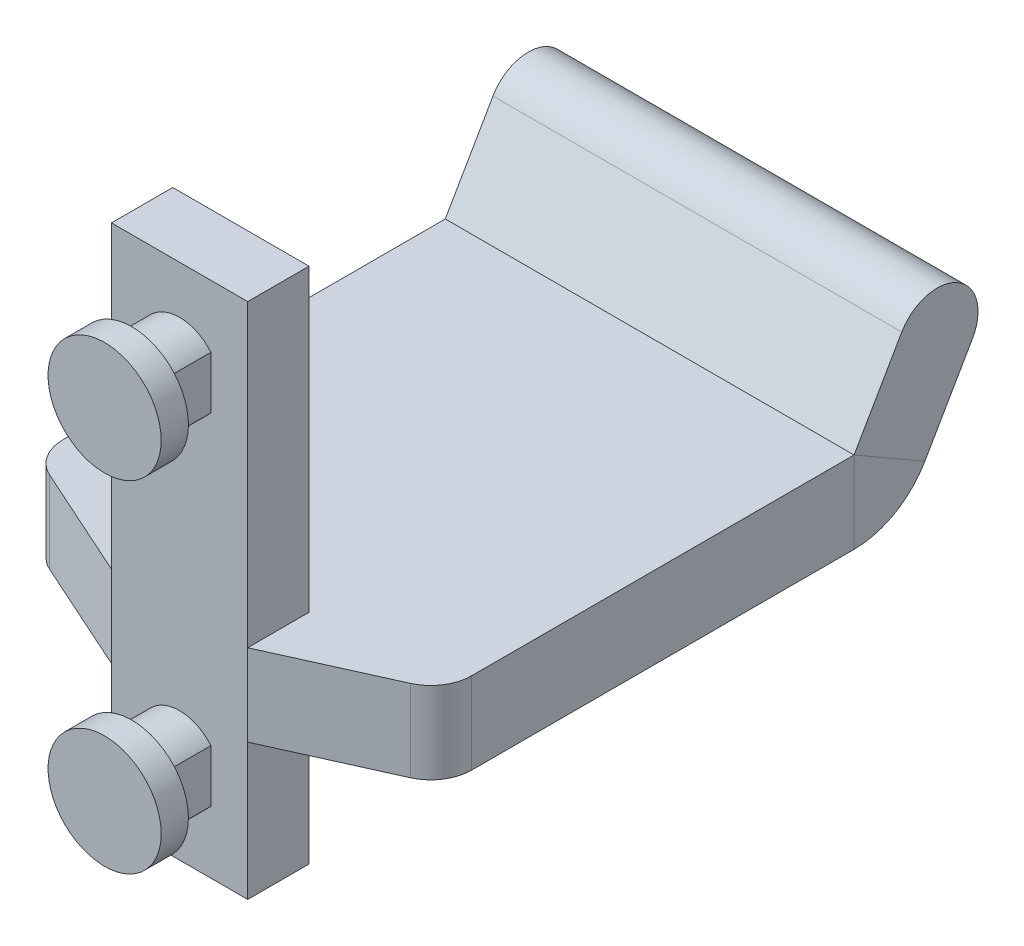
from build123d import *

# Parameters (mm, degrees)
EXTRUDE_1_DEPTH   = 3.5
EXTRUDE_1_2_DEPTH = 3.5
SKETCH_2_R        = 4.15
EXTRUDE_2_DEPTH   = 2
SKETCH_3_W        = 10
SKETCH_3_H        = 38
EXTRUDE_3_DEPTH   = 4.5
SKETCH_5_W        = 30
SKETCH_5_H        = 6
EXTRUDE_4_DEPTH   = 25
EXTRUDE_5_DEPTH   = 6
SKETCH_10_W       = 30
SKETCH_10_H       = 6
SKETCH_11_W       = 30
SKETCH_11_H       = 3
REVOLVE_1_ANGLE   = 180
FILLET_1_R        = 3


with BuildPart() as part:
    # 草图1 → 凸台-拉伸1 (new body)
    with BuildSketch(Plane.XY):
        with BuildLine():
            Line((-2.3, 1.926136028), (-2.3, -1.926136028))
            ThreePointArc((-2.3, -1.926136028), (0, -3), (2.3, -1.926136028))
            Line((2.3, -1.926136028), (2.3, 1.926136028))
            ThreePointArc((2.3, 1.926136028), (0, 3), (-2.3, 1.926136028))
        make_face()
    extrude(amount=EXTRUDE_1_DEPTH)



with BuildPart() as body_2:
    # 草图1 → Extrude 1 2 (new body)
    with BuildSketch(Plane.XY):
        with BuildLine():
            Line((-2.3, -23.073863972), (-2.3, -26.926136028))
            ThreePointArc((-2.3, -26.926136028), (0, -28), (2.3, -26.926136028))
            Line((2.3, -26.926136028), (2.3, -23.073863972))
            ThreePointArc((2.3, -23.073863972), (0, -22), (-2.3, -23.073863972))
        make_face()
    extrude(amount=EXTRUDE_1_2_DEPTH)


with BuildPart() as part_1:
    add(part.part)

    add(body_2.part)  # 凸台-拉伸2 merges body 2
    # 草图2 → 凸台-拉伸2 (add)
    with BuildSketch(Plane.XY.offset(3.5)):
        Circle(SKETCH_2_R)
        with Locations((0, -25)):
            Circle(SKETCH_2_R)
    extrude(amount=EXTRUDE_2_DEPTH)

    # 草图3 → 凸台-拉伸3 (add)
    with BuildSketch(Plane(origin=(0, 0, 0), x_dir=(-1, 0, 0), z_dir=(0, 0, -1))):
        with Locations((0, -12.5)):
            Rectangle(SKETCH_3_W, SKETCH_3_H)
    extrude(amount=EXTRUDE_3_DEPTH)

    # 草图5 → 凸台-拉伸4 (add)
    with BuildSketch(Plane(origin=(0, 0, -4.5), x_dir=(-1, 0, 0), z_dir=(0, 0, -1))):
        with Locations((0, -18.5)):
            Rectangle(SKETCH_5_W, SKETCH_5_H)
    extrude(amount=EXTRUDE_4_DEPTH)

    # 草图8 → 凸台-拉伸5 (add)
    with BuildSketch(Plane(origin=(0, -15.5, 0), x_dir=(1, 0, 0), z_dir=(0, 1, 0))):
        Polygon((15, 4.5), (5, 4.5), (5, 0), align=None)
        Polygon((-15, 4.5), (-5, 4.5), (-5, 0), align=None)
    extrude(amount=-EXTRUDE_5_DEPTH)

    # 扫描1: sweep along a path in 草图9
    with BuildLine(Plane(origin=(0, 0, 0), x_dir=(0, 0, -1), z_dir=(1, 0, 0))) as sweep_1_path:
        Line((29.5, -18.5), (34.5, -18.5))
        ThreePointArc((34.5, -18.5), (36, -18.098076211), (37.098076211, -17))
        Line((37.098076211, -17), (40.598076211, -10.937822174))
    # 草图10 → 扫描1 (sweep)
    with BuildSketch(Plane(origin=(0, 0, -29.5), x_dir=(-1, 0, 0), z_dir=(0, 0, -1))):
        with Locations((0, -18.5)):
            Rectangle(SKETCH_10_W, SKETCH_10_H)
    sweep(path=sweep_1_path.line)

    # 草图11 → 旋转1 (revolve)
    with BuildSketch(Plane(origin=(0, 9.376116042, -5.413303121), x_dir=(1, 0, 0), z_dir=(0, 0.866025404, -0.5))):
        with Locations((0, 42.127876431)):
            Rectangle(SKETCH_11_W, SKETCH_11_H)
    revolve(axis=Axis((15, -10.937822174, -40.598076211), (1, 0, 0)), revolution_arc=REVOLVE_1_ANGLE)

    # 圆角1
    fillet_1_edges = [part_1.edges().sort_by_distance(p)[0] for p in [
        (15, -18.5, -4.5),
        (-15, -18.5, -4.5),
    ]]
    fillet(fillet_1_edges, radius=FILLET_1_R)


solid = part_1.part
